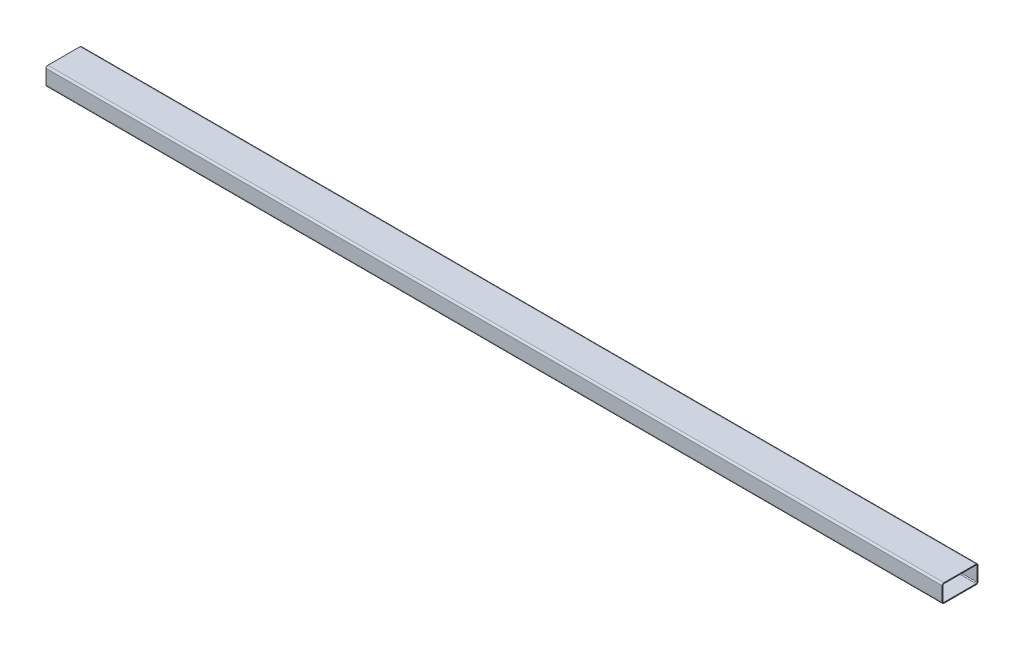
from build123d import *

# Parameters (mm, degrees)
TUBE_DU_STOCK_GUELT_CONFIGURED_1_DEPTH = 2000


with BuildPart() as part:
    # Esquisse13 → Tube du stock guelt - configured_1 (new body)
    with BuildSketch(Plane.YZ.offset(-1000)):
        with BuildLine():
            Line((16, -40), (-16, -40))
            ThreePointArc((-16, -40), (-18.828427125, -38.828427125), (-20, -36))
            Line((-20, -36), (-20, 36))
            ThreePointArc((-20, 36), (-18.828427125, 38.828427125), (-16, 40))
            Line((-16, 40), (16, 40))
            ThreePointArc((16, 40), (18.828427125, 38.828427125), (20, 36))
            Line((20, 36), (20, -36))
            ThreePointArc((20, -36), (18.828427125, -38.828427125), (16, -40))
        make_face()
        with BuildLine():
            Line((16, -38), (-16, -38))
            ThreePointArc((-16, -38), (-17.414213562, -37.414213562), (-18, -36))
            Line((-18, -36), (-18, 36))
            ThreePointArc((-18, 36), (-17.414213562, 37.414213562), (-16, 38))
            Line((-16, 38), (16, 38))
            ThreePointArc((16, 38), (17.414213562, 37.414213562), (18, 36))
            Line((18, 36), (18, -36))
            ThreePointArc((18, -36), (17.414213562, -37.414213562), (16, -38))
        make_face(mode=Mode.SUBTRACT)
    extrude(amount=TUBE_DU_STOCK_GUELT_CONFIGURED_1_DEPTH)


solid = part.part
